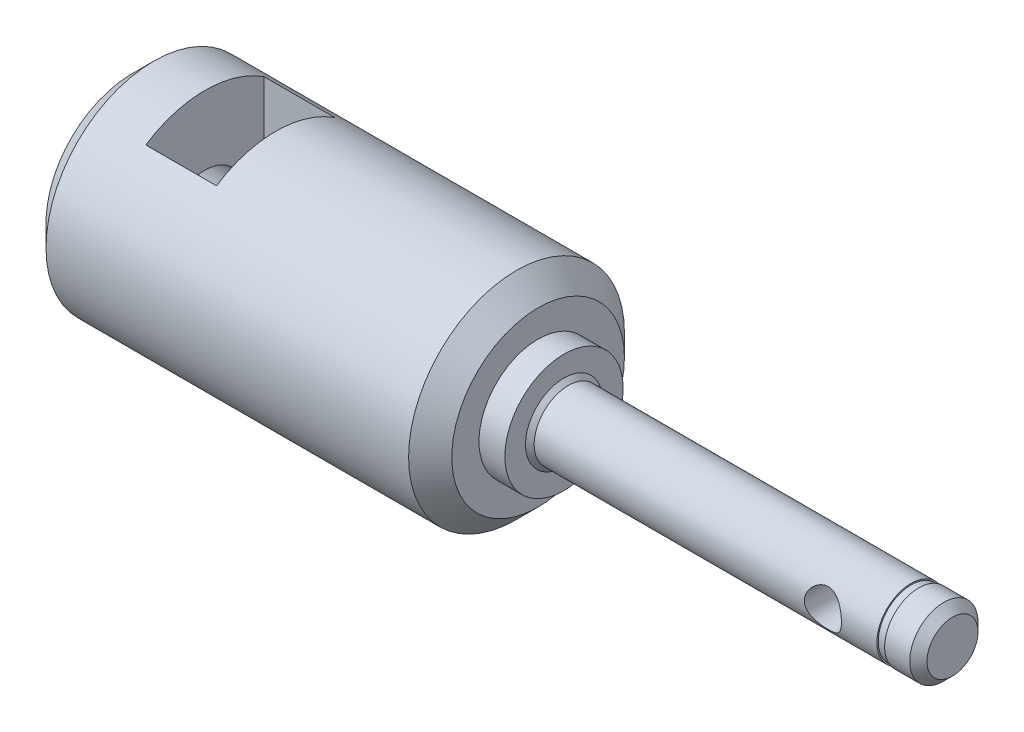
from build123d import *

# Parameters (mm, degrees)
SKETCH1_R               = 12.5
BOSS_EXTRUDE1_DEPTH     = 50
SKETCH6_R               = 12.5
SKETCH6_R_2             = 6.85
CUT_EXTRUDE4_DEPTH      = 3
SKETCH7_R               = 3.955
BOSS_EXTRUDE3_DEPTH     = 45
CUT_EXTRUDE5_DEPTH      = 54.033008589
CUT_EXTRUDE5_DEPTH_BACK = 54.033008589
SKETCH8_R               = 2.15
SKETCH9_R               = 3.97
SKETCH9_R_2             = 3.8
CUT_EXTRUDE6_DEPTH      = 0.9
SKETCH10_R              = 4
CUT_EXTRUDE7_DEPTH      = 20
CHAMFER2_SIZE           = 2.5
CHAMFER3_SIZE           = 2.5
CHAMFER4_SIZE           = 1
SKETCH2_R               = 8.963089754
BOSS_EXTRUDE2_DEPTH     = 35
SKETCH12_R              = 9.5
SKETCH12_R_2            = 4.5
BOSS_EXTRUDE4_DEPTH     = 9
CUT_EXTRUDE8_DEPTH      = 54.033008589
CUT_EXTRUDE8_DEPTH_BACK = 54.033008589
SKETCH11_W              = 8.2
SKETCH11_H              = 13.7
SKETCH13_R              = 4.5
CUT_EXTRUDE9_DEPTH      = 17
CHAMFER5_SIZE           = 0.5


with BuildPart() as part:
    # Sketch1 → Boss-Extrude1 (new body)
    with BuildSketch(Plane(origin=(0, 0, 0), x_dir=(0, 0, -1), z_dir=(1, 0, 0))):
        Circle(SKETCH1_R)
    extrude(amount=-BOSS_EXTRUDE1_DEPTH)

    # Sketch6 → Cut-Extrude4 (cut)
    with BuildSketch(Plane(origin=(0, 0, 0), x_dir=(0, 0, -1), z_dir=(1, 0, 0))):
        Circle(SKETCH6_R)
        Circle(SKETCH6_R_2, mode=Mode.SUBTRACT)
    extrude(amount=-CUT_EXTRUDE4_DEPTH, mode=Mode.SUBTRACT)

    # Sketch7 → Boss-Extrude3 (add)
    with BuildSketch(Plane(origin=(0, 0, 0), x_dir=(0, 0, -1), z_dir=(1, 0, 0))):
        Circle(SKETCH7_R)
    extrude(amount=BOSS_EXTRUDE3_DEPTH)

    # Sketch8 → Cut-Extrude5 (cut, two sides: drawn at the far end of the back side and taken through both)
    with BuildSketch(Plane.XY.offset(-CUT_EXTRUDE5_DEPTH_BACK)):
        with Locations((33.94, 0)):
            Circle(SKETCH8_R)
    extrude(amount=CUT_EXTRUDE5_DEPTH + CUT_EXTRUDE5_DEPTH_BACK, mode=Mode.SUBTRACT)

    # Sketch9 → Cut-Extrude6 (cut)
    with BuildSketch(Plane(origin=(40.2, 0, 0), x_dir=(0, 0, -1), z_dir=(1, 0, 0))):
        Circle(SKETCH9_R)
        Circle(SKETCH9_R_2, mode=Mode.SUBTRACT)
    extrude(amount=CUT_EXTRUDE6_DEPTH, mode=Mode.SUBTRACT)

    # Sketch10 → Cut-Extrude7 (cut)
    with BuildSketch(Plane.ZY.offset(50)):
        Circle(SKETCH10_R)
    extrude(amount=-CUT_EXTRUDE7_DEPTH, mode=Mode.SUBTRACT)

    # Chamfer2
    chamfer2_edges = [part.edges().sort_by_distance(p)[0] for p in [
        (-50, 0, 12.5),
    ]]
    chamfer(chamfer2_edges, length=CHAMFER2_SIZE)

    # Chamfer3
    chamfer3_edges = [part.edges().sort_by_distance(p)[0] for p in [
        (-3, 0, 12.5),
    ]]
    chamfer(chamfer3_edges, length=CHAMFER3_SIZE)

    # Chamfer4
    chamfer4_edges = [part.edges().sort_by_distance(p)[0] for p in [
        (45, 0, 3.955),
    ]]
    chamfer(chamfer4_edges, length=CHAMFER4_SIZE)

    # Sketch2 → Boss-Extrude2 (add)
    with BuildSketch(Plane.ZY.offset(50)):
        Circle(SKETCH2_R)
    extrude(amount=-BOSS_EXTRUDE2_DEPTH)

    # Sketch12 → Boss-Extrude4 (add)
    with BuildSketch(Plane.ZY.offset(50)):
        Circle(SKETCH12_R)
        Circle(SKETCH12_R_2, mode=Mode.SUBTRACT)
    extrude(amount=-BOSS_EXTRUDE4_DEPTH)

    # Sketch11 → Cut-Extrude8 (cut, two sides: drawn at the far end of the back side and taken through both)
    with BuildSketch(Plane(origin=(0, 0, 0), x_dir=(1, 0, 0), z_dir=(0, 1, 0)).offset(-CUT_EXTRUDE8_DEPTH_BACK)):
        with Locations((-37.5, 0)):
            Rectangle(SKETCH11_W, SKETCH11_H)
    extrude(amount=CUT_EXTRUDE8_DEPTH + CUT_EXTRUDE8_DEPTH_BACK, mode=Mode.SUBTRACT)

    # Sketch13 → Cut-Extrude9 (cut)
    with BuildSketch(Plane.ZY.offset(50)):
        Circle(SKETCH13_R)
    extrude(amount=-CUT_EXTRUDE9_DEPTH, mode=Mode.SUBTRACT)

    # Chamfer5
    chamfer5_edges = [part.edges().sort_by_distance(p)[0] for p in [
        (0, 0, 3.955),
    ]]
    chamfer(chamfer5_edges, length=CHAMFER5_SIZE)


solid = part.part
